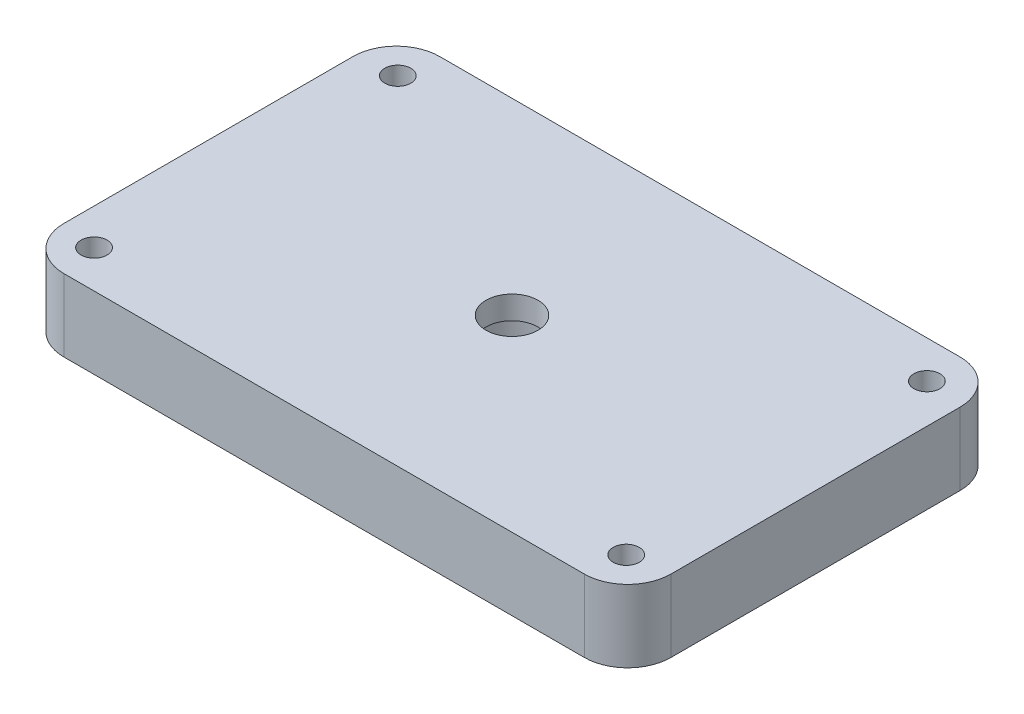
from build123d import *

# Parameters (mm, degrees)
SKETCH1_R           = 1.143
BOSS_EXTRUDE1_DEPTH = 6.35
SKETCH2_R           = 3.81
CUT_EXTRUDE1_DEPTH  = 4.318
SKETCH3_R           = 2.286
CUT_EXTRUDE2_DEPTH  = 4.318


with BuildPart() as part:
    # Sketch1 → Boss-Extrude1 (new body)
    with BuildSketch(Plane(origin=(0, 0, 0), x_dir=(1, 0, 0), z_dir=(0, 1, 0))):
        with BuildLine():
            Line((-22.86, 16.51), (22.86, 16.51))
            ThreePointArc((22.86, 16.51), (25.554076836, 15.394076836), (26.67, 12.7))
            Line((26.67, 12.7), (26.67, -12.7))
            ThreePointArc((26.67, -12.7), (25.554076836, -15.394076836), (22.86, -16.51))
            Line((22.86, -16.51), (18.7325, -16.51))
            Line((18.7325, -16.51), (-18.7325, -16.51))
            Line((-18.7325, -16.51), (-22.86, -16.51))
            ThreePointArc((-22.86, -16.51), (-25.554076836, -15.394076836), (-26.67, -12.7))
            Line((-26.67, -12.7), (-26.67, 12.7))
            ThreePointArc((-26.67, 12.7), (-25.554076836, 15.394076836), (-22.86, 16.51))
        make_face()
        with Locations((-23.241, 13.208)):
            Circle(SKETCH1_R, mode=Mode.SUBTRACT)
        with Locations((23.241, 13.208)):
            Circle(SKETCH1_R, mode=Mode.SUBTRACT)
        with Locations((23.241, -13.208)):
            Circle(SKETCH1_R, mode=Mode.SUBTRACT)
        with Locations((-23.50753981, -13.208)):
            Circle(SKETCH1_R, mode=Mode.SUBTRACT)
    extrude(amount=BOSS_EXTRUDE1_DEPTH)

    # Sketch2 → Cut-Extrude1 (cut)
    with BuildSketch(Plane.XZ):
        Circle(SKETCH2_R)
    extrude(amount=-CUT_EXTRUDE1_DEPTH, mode=Mode.SUBTRACT)

    # Sketch3 → Cut-Extrude2 (cut)
    with BuildSketch(Plane(origin=(0, 4.318, 0), x_dir=(-1, 0, 0), z_dir=(0, -1, 0))):
        Circle(SKETCH3_R)
    extrude(amount=-CUT_EXTRUDE2_DEPTH, mode=Mode.SUBTRACT)


solid = part.part
